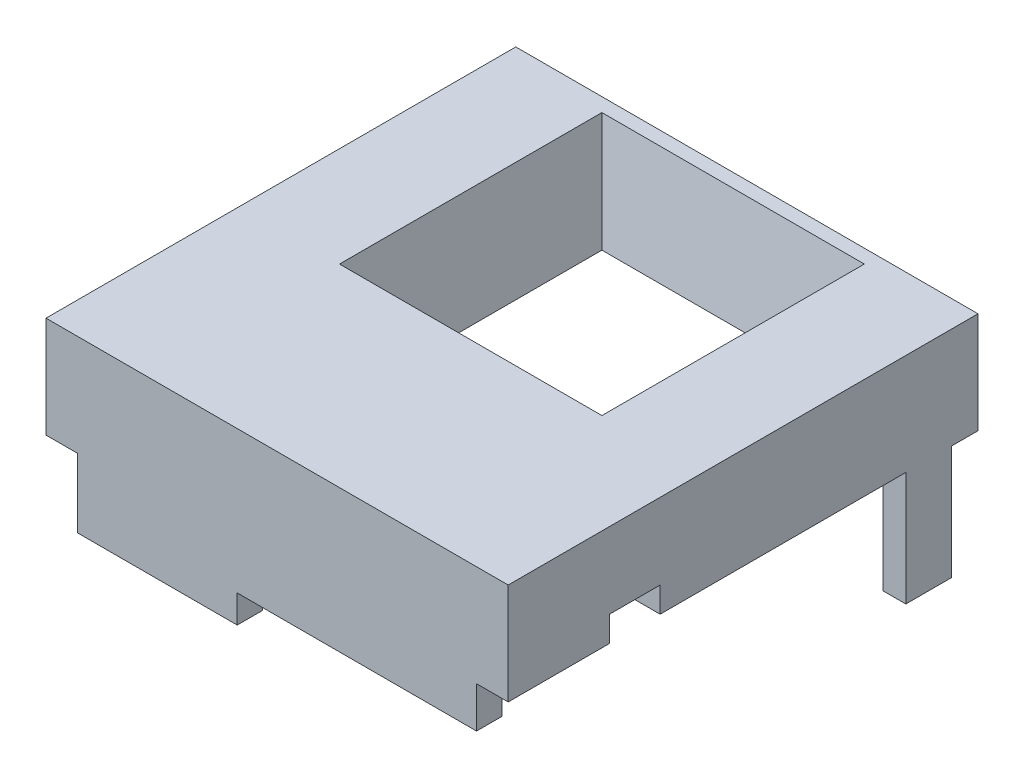
from build123d import *

# Parameters (mm, degrees)
SKETCH1_W          = 36.5
SKETCH1_H          = 37.1
BODY_DEPTH         = 8
SKETCH2_W          = 2
SKETCH2_H          = 4
FEMALE_TABS_DEPTH  = 2
SKETCH3_W          = 1.8
SKETCH3_H          = 3.6
MALE_TABS_DEPTH    = 9
SKETCH5_W          = 17.9
SKETCH5_H          = 17.9
SIPM_WINDOW_DEPTH  = 8
SIPM_WINDOW_TAPER  = -10
CUT_EXTRUDE2_DEPTH = 6
SKETCH7_W          = 18.9
SKETCH7_H          = 2
RIGHT_DROP_DEPTH   = 3.24
SKETCH8_W          = 12.6
SKETCH8_H          = 2
LEFT_DROP_DEPTH    = 5.44


with BuildPart() as part:
    # Sketch1 → Body (new body)
    with BuildSketch(Plane(origin=(0, 0, 0), x_dir=(1, 0, 0), z_dir=(0, 1, 0))):
        with Locations((18.25, -18.55)):
            Rectangle(SKETCH1_W, SKETCH1_H)
    extrude(amount=BODY_DEPTH)

    # Sketch2 → Female Tabs (cut)
    with BuildSketch(Plane(origin=(0, 0, 0), x_dir=(-1, 0, 0), z_dir=(0, -1, 0))):
        with Locations((-1, -4.1)):
            Rectangle(SKETCH2_W, SKETCH2_H)
        with Locations((-35.5, -27.1)):
            Rectangle(SKETCH2_W, SKETCH2_H)
    extrude(amount=-FEMALE_TABS_DEPTH, mode=Mode.SUBTRACT)

    # Sketch3 → Male Tabs (add)
    with BuildSketch(Plane(origin=(0, 0, 0), x_dir=(-1, 0, 0), z_dir=(0, -1, 0))):
        with Locations((-0.9, -27.3)):
            Rectangle(SKETCH3_W, SKETCH3_H)
        with Locations((-35.6, -3.9)):
            Rectangle(SKETCH3_W, SKETCH3_H)
    extrude(amount=MALE_TABS_DEPTH)

    # Sketch5 → SiPM Window (cut)
    with BuildSketch(Plane(origin=(0, 0, 0), x_dir=(-1, 0, 0), z_dir=(0, -1, 0))):
        with Locations((-18.25, -11.45)):
            Rectangle(SKETCH5_W, SKETCH5_H)
    extrude(amount=-SIPM_WINDOW_DEPTH, taper=SIPM_WINDOW_TAPER, mode=Mode.SUBTRACT)

    # Sketch6 → Cut-Extrude2 (cut)
    with BuildSketch(Plane.XZ):
        Polygon((34, 1.5), (29.2, 1.5), (29.2, 22.4), (7.3, 22.4), (7.3, 1.5), (2.5, 1.5), (2.5, 35.1), (34, 35.1), align=None)
    extrude(amount=-CUT_EXTRUDE2_DEPTH, mode=Mode.SUBTRACT)

    # Sketch7 → Right Drop (add)
    with BuildSketch(Plane.XZ):
        with Locations((24.55, 36.1)):
            Rectangle(SKETCH7_W, SKETCH7_H)
    extrude(amount=RIGHT_DROP_DEPTH)

    # Sketch8 → Left Drop (add)
    with BuildSketch(Plane.XZ):
        with Locations((8.8, 36.1)):
            Rectangle(SKETCH8_W, SKETCH8_H)
    extrude(amount=LEFT_DROP_DEPTH)


solid = part.part
